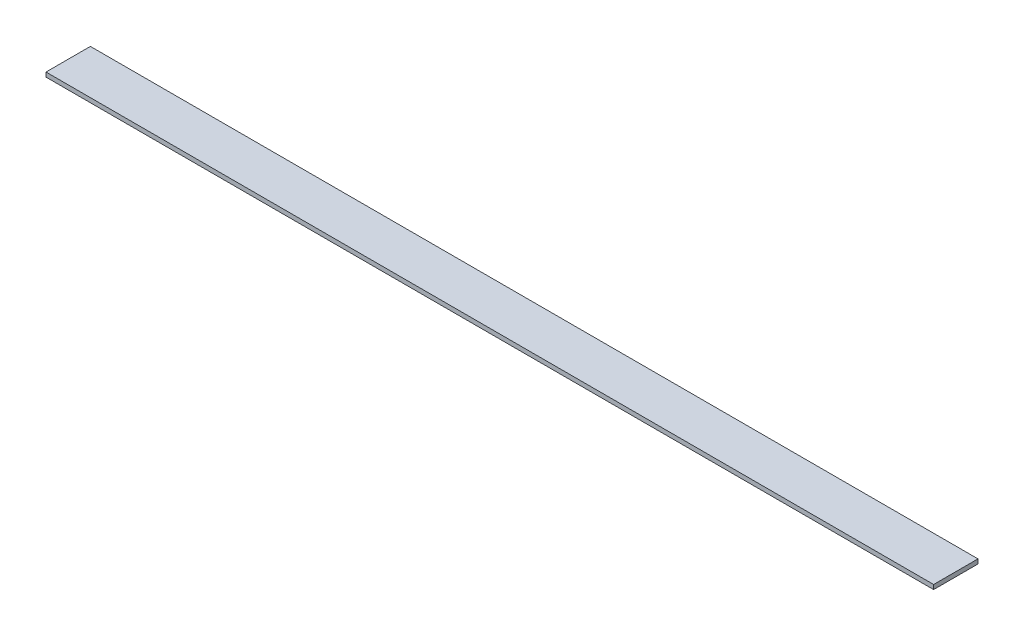
from build123d import *

# Parameters (mm, degrees)
SKETCH1_W           = 6000
SKETCH1_H           = 300
BOSS_EXTRUDE1_DEPTH = 30


with BuildPart() as part:
    # Sketch1 → Boss-Extrude1 (new body)
    with BuildSketch(Plane(origin=(0, 0, 0), x_dir=(1, 0, 0), z_dir=(0, 1, 0))):
        Rectangle(SKETCH1_W, SKETCH1_H)
    extrude(amount=BOSS_EXTRUDE1_DEPTH)


solid = part.part
